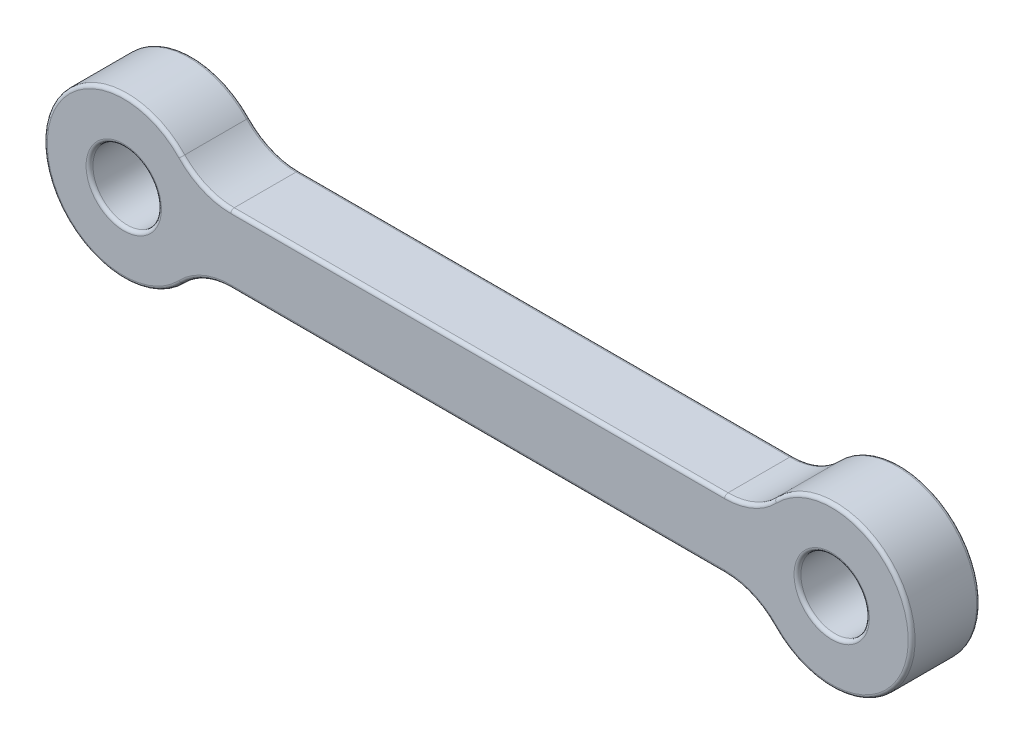
from build123d import *

# Parameters (mm, degrees)
SKETCH1_R           = 3.5
SKETCH1_R_2         = 1.5
BOSS_EXTRUDE1_DEPTH = 1.5
FILLET1_R           = 3
FILLET2_R           = 0.15


with BuildPart() as part:
    # Sketch1 → Boss-Extrude1 (new body, symmetric)
    with BuildSketch(Plane.XY):
        Circle(SKETCH1_R)
        Circle(SKETCH1_R_2, mode=Mode.SUBTRACT)
        with BuildLine():
            ThreePointArc((3.5, 0), (3.414525722, -0.768774411), (3.16227766, -1.5))
            Line((3.16227766, -1.5), (27.83772234, -1.5))
            ThreePointArc((27.83772234, -1.5), (27.5, 0), (27.83772234, 1.5))
            Line((27.83772234, 1.5), (3.16227766, 1.5))
            ThreePointArc((3.16227766, 1.5), (3.414525722, 0.768774411), (3.5, 0))
        make_face()
        with Locations((31, 0)):
            Circle(SKETCH1_R)
        with Locations((31, 0)):
            Circle(SKETCH1_R_2, mode=Mode.SUBTRACT)
    extrude(amount=BOSS_EXTRUDE1_DEPTH, both=True)

    # Fillet1
    fillet1_edges = [part.edges().sort_by_distance(p)[0] for p in [
        (27.83772234, 1.5, 0),
        (27.83772234, -1.5, 0),
        (3.16227766, -1.5, 0),
        (3.16227766, 1.5, 0),
    ]]
    fillet(fillet1_edges, radius=FILLET1_R)

    # Fillet2
    fillet2_edges = [part.edges().sort_by_distance(p)[0] for p in [
        (15.5, -1.5, -1.5),
        (15.5, -1.5, 1.5),
        (-1.5, 0, 1.5),
        (-3.5, 0, -1.5),
        (-3.5, 0, 1.5),
        (34.5, 0, -1.5),
        (34.5, 0, 1.5),
        (29.5, 0, 1.5),
        (15.5, 1.5, -1.5),
        (15.5, 1.5, 1.5),
        (3.513718949, -1.740401367, -1.5),
        (3.513718949, -1.740401367, 1.5),
        (27.486281051, -1.740401367, -1.5),
        (27.486281051, -1.740401367, 1.5),
        (27.486281051, 1.740401367, -1.5),
        (27.486281051, 1.740401367, 1.5),
        (3.513718949, 1.740401367, -1.5),
        (3.513718949, 1.740401367, 1.5),
        (29.5, 0, -1.5),
        (-1.5, 0, -1.5),
    ]]
    fillet(fillet2_edges, radius=FILLET2_R)


solid = part.part
